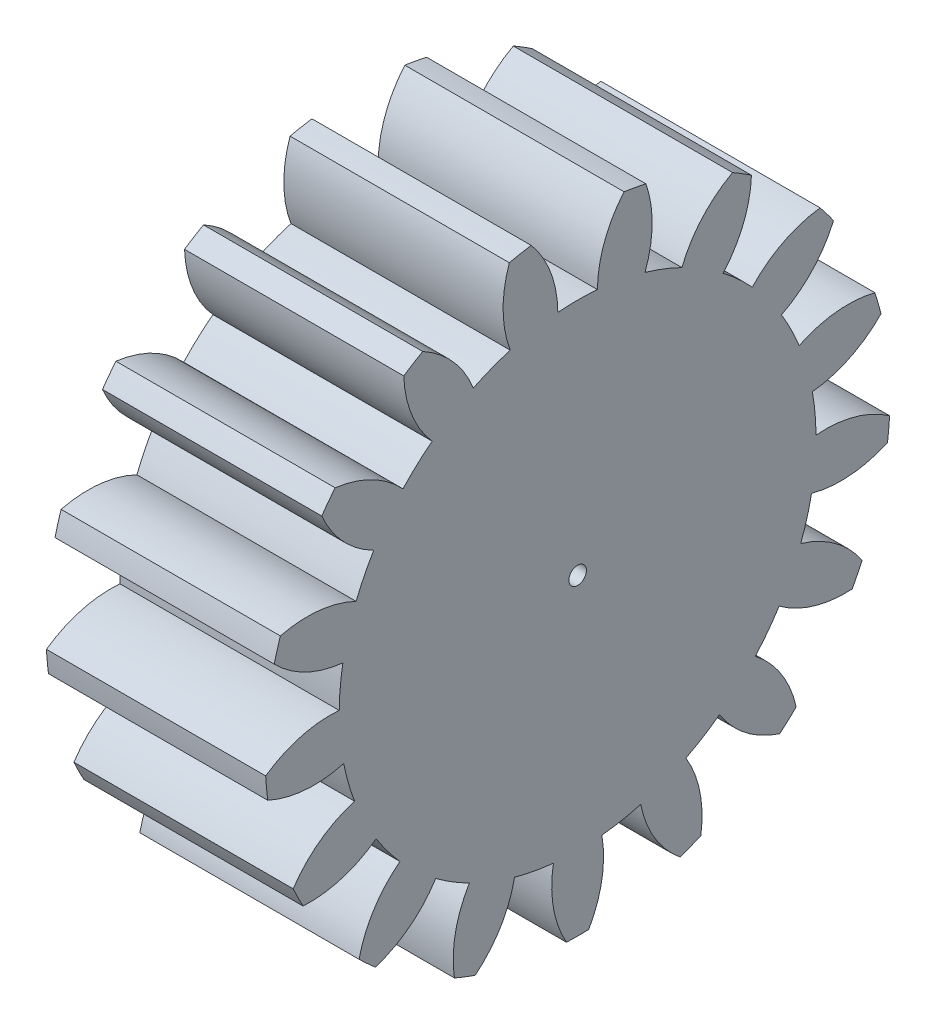
from build123d import *

# Parameters (mm, degrees)
BASPROSKE_W     = 10
BASPROSKE_H     = 14.25
TOOTHCUT_DEPTH  = 23.497222051
TEETHCUTS_COUNT = 17
TEETHCUTS_ANGLE = 338.823529412
BORSKE_R        = 0.4
BORE_DEPTH      = 50.0000508


with BuildPart() as part:
    # BasProSke → Base-Revolve (revolve)
    with BuildSketch(Plane(origin=(0, 0, 0), x_dir=(1, 0, 0), z_dir=(0, 1, 0)), mode=Mode.PRIVATE) as base_revolve_sk:
        with Locations((5, 7.125)):
            Rectangle(BASPROSKE_W, BASPROSKE_H)
    revolve(base_revolve_sk.sketch.rotate(Axis((-10, 0, 0), (1, 0, 0)), 180), axis=Axis((-10, 0, 0), (1, 0, 0)))

    # TooCutSke → ToothCut (cut, through all)
    with BuildSketch(Plane(origin=(0, 0, 0), x_dir=(0, 0, -1), z_dir=(1, 0, 0))):
        with BuildLine():
            ThreePointArc((0.902146084, 10.836512744), (0, 10.874), (-0.902146084, 10.836512744))
            ThreePointArc((-0.902146084, 10.836512744), (-1.229496811, 12.584878605), (-2.137378415, 14.114484003))
            ThreePointArc((-2.137378415, 14.114484003), (0, 14.2754), (2.137378415, 14.114484003))
            ThreePointArc((2.137378415, 14.114484003), (1.229496811, 12.584878605), (0.902146084, 10.836512744))
        make_face()
    toothcut = extrude(amount=TOOTHCUT_DEPTH, mode=Mode.SUBTRACT)

    # TeethCuts: ToothCut ×17 about axis
    teethcuts_axis = Axis((-10, 0, 0), (1, 0, 0))
    for i in range(1, TEETHCUTS_COUNT):
        add(toothcut.rotate(teethcuts_axis, i * TEETHCUTS_ANGLE / (TEETHCUTS_COUNT - 1)), mode=Mode.SUBTRACT)

    # BorSke → Bore (cut, symmetric)
    with BuildSketch(Plane(origin=(0, 0, 0), x_dir=(0, 0, -1), z_dir=(1, 0, 0))):
        with Locations(Location((0, 0, 0), (0, 0, 180))):
            Circle(BORSKE_R)
    extrude(amount=BORE_DEPTH, both=True, mode=Mode.SUBTRACT)


solid = part.part
